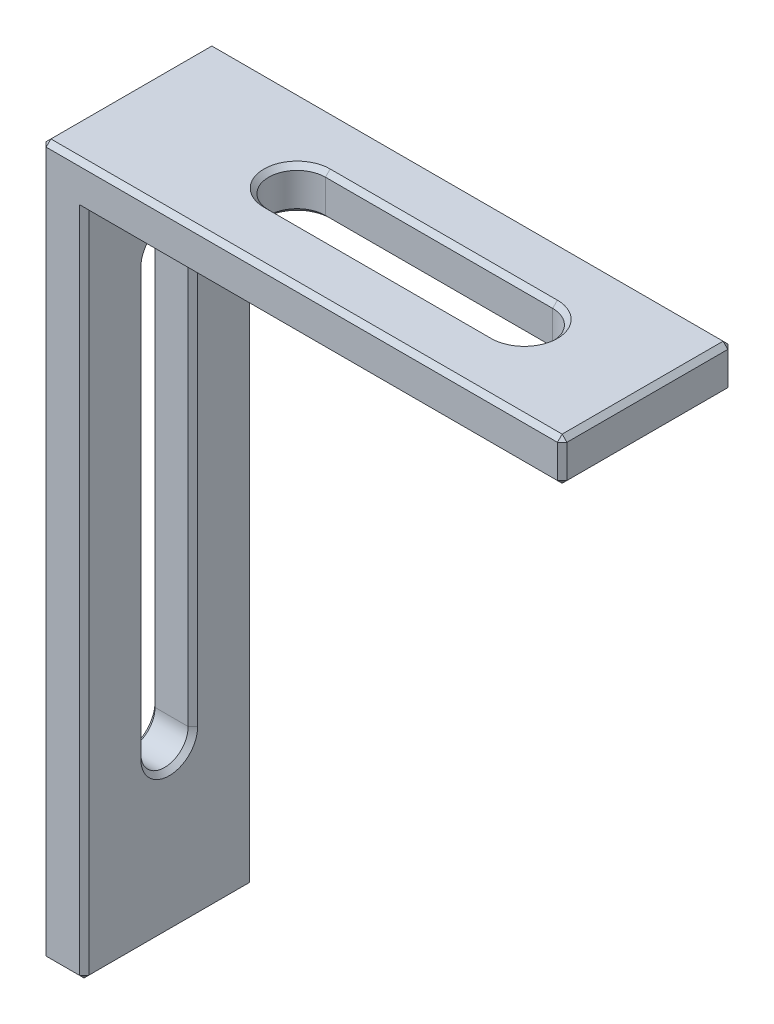
from build123d import *

# Parameters (mm, degrees)
BOSS_EXTRU_1_DEPTH      = 36
ENL_V_MAT_EXTRU_1_DEPTH = 36
ENL_V_MAT_EXTRU_2_DEPTH = 36
CHANFREIN1_SIZE         = 1


with BuildPart() as part:
    # Esquisse1 → Boss.-Extru.1 (new body)
    with BuildSketch(Plane.XY):
        Polygon((0, 0), (0, 150), (110, 150), (110, 141), (9, 141), (9, 0), align=None)
    extrude(amount=BOSS_EXTRU_1_DEPTH)

    # Esquisse2 → Enlèv. mat.-Extru.1 (cut)
    with BuildSketch(Plane.ZY):
        with BuildLine():
            Line((23, 125), (23, 35))
            ThreePointArc((23, 35), (18, 30), (13, 35))
            Line((13, 35), (13, 125))
            ThreePointArc((13, 125), (18, 130), (23, 125))
        make_face()
    extrude(amount=-ENL_V_MAT_EXTRU_1_DEPTH, mode=Mode.SUBTRACT)

    # Esquisse3 → Enlèv. mat.-Extru.2 (cut)
    with BuildSketch(Plane(origin=(0, 150, 0), x_dir=(1, 0, 0), z_dir=(0, 1, 0))):
        with BuildLine():
            Line((36, -12), (84, -12))
            ThreePointArc((84, -12), (90, -18), (84, -24))
            Line((84, -24), (36, -24))
            ThreePointArc((36, -24), (30, -18), (36, -12))
        make_face()
    extrude(amount=-ENL_V_MAT_EXTRU_2_DEPTH, mode=Mode.SUBTRACT)

    # Chanfrein1
    chanfrein1_edges = [part.edges().sort_by_distance(p)[0] for p in [
        (59.5, 141, 36),
        (0, 0, 18),
        (0, 150, 18),
        (110, 150, 18),
        (110, 141, 18),
        (9, 0, 18),
        (110, 145.5, 36),
        (55, 150, 36),
        (0, 75, 36),
        (9, 130, 18),
        (9, 80, 23),
        (9, 30, 18),
        (9, 80, 13),
        (0, 130, 18),
        (0, 80, 13),
        (0, 30, 18),
        (0, 80, 23),
        (4.5, 0, 36),
        (30, 141, 18),
        (60, 141, 12),
        (90, 141, 18),
        (60, 141, 24),
        (30, 150, 18),
        (60, 150, 24),
        (90, 150, 18),
        (60, 150, 12),
        (0, 75, 0),
        (55, 150, 0),
        (110, 145.5, 0),
        (9, 70.5, 36),
        (59.5, 141, 0),
        (9, 70.5, 0),
        (4.5, 0, 0),
    ]]
    chamfer(chanfrein1_edges, length=CHANFREIN1_SIZE)


solid = part.part
